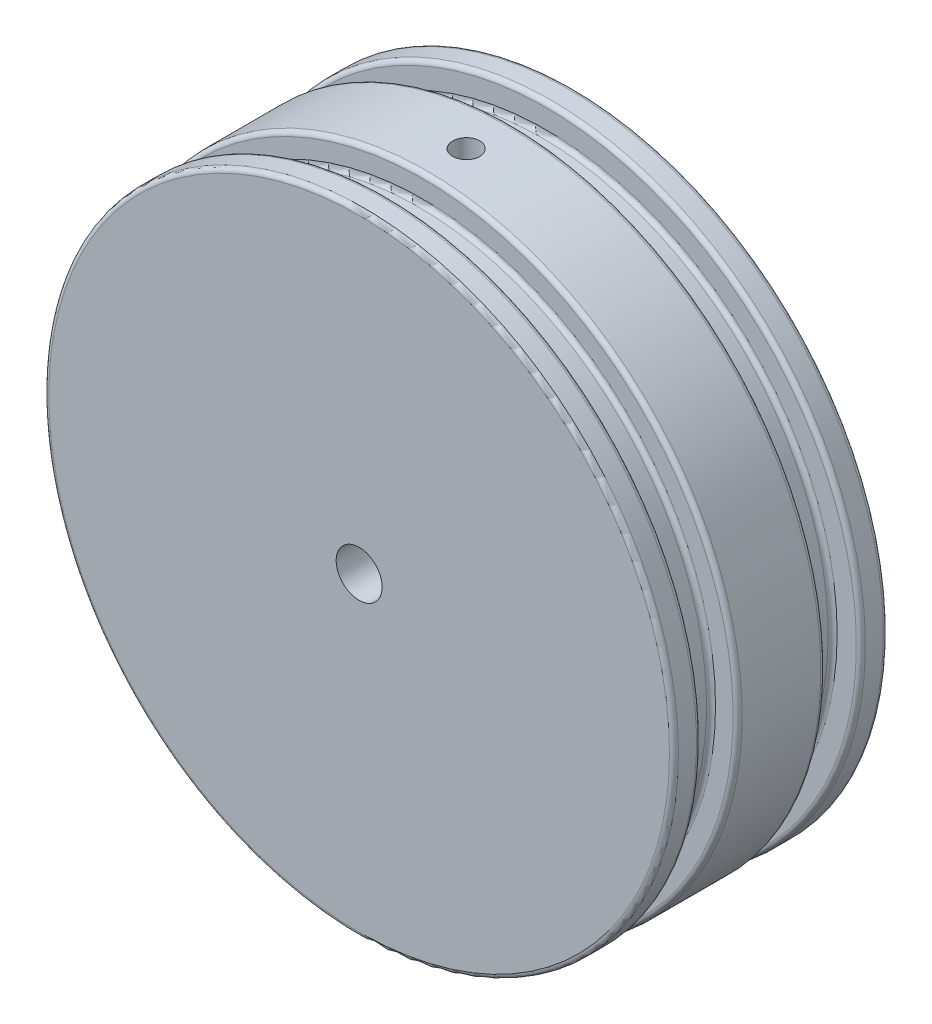
from build123d import *

# Parameters (mm, degrees)
SKETCH1_R                   = 69.9
BOSS_EXTRUDE1_DEPTH         = 20
SKETCH8_R                   = 69.9
BOSS_EXTRUDE2_DEPTH         = 27.5
SKETCH7_W                   = 5.9
SKETCH7_H                   = 8.13
SKETCH7_W_2                 = 6.2648
SKETCH7_H_2                 = 7.87
FILLET1_R                   = 1
M12X1_75_TAPPED_HOLE1_D     = 10.2
M12X1_75_TAPPED_HOLE1_DEPTH = 17.5
M12X1_75_TAPPED_HOLE1_TIP   = 3.064389157
M12X1_75_TAPPED_HOLE2_D     = 10.2
M12X1_75_TAPPED_HOLE2_DEPTH = 17.5
M12X1_75_TAPPED_HOLE2_TIP   = 3.064389157
F_6_0MM_DOWEL_HOLE1_D       = 6
F_6_0MM_DOWEL_HOLE1_DEPTH   = 27
F_6_0MM_DOWEL_HOLE1_TIP     = 1.802581857
F_6_0MM_DOWEL_HOLE2_D       = 6
F_6_0MM_DOWEL_HOLE2_DEPTH   = 23.75
F_6_0MM_DOWEL_HOLE2_TIP     = 1.802581857


with BuildPart() as part:
    # Sketch1 → Boss-Extrude1 (new body)
    with BuildSketch(Plane.XY):
        Circle(SKETCH1_R)
    extrude(amount=BOSS_EXTRUDE1_DEPTH)

    # Sketch8 → Boss-Extrude2 (add)
    with BuildSketch(Plane(origin=(0, 0, 0), x_dir=(-1, 0, 0), z_dir=(0, 0, -1))):
        Circle(SKETCH8_R)
    extrude(amount=BOSS_EXTRUDE2_DEPTH)

    # Sketch7 → Cut-Revolve2 (revolve, cut)
    with BuildSketch(Plane(origin=(0, 0, 0), x_dir=(1, 0, 0), z_dir=(0, 1, 0))):
        with Locations((66.95, -9.935)):
            Rectangle(SKETCH7_W, SKETCH7_H)
        with Locations((66.7676, 17.565)):
            Rectangle(SKETCH7_W_2, SKETCH7_H_2)
    revolve(axis=Axis((0, 0, 0), (0, 0, 1)), mode=Mode.SUBTRACT)

    # Fillet1
    fillet1_edges = [part.edges().sort_by_distance(p)[0] for p in [
        (-69.9, 0, 5.87),
        (-64, 0, 5.87),
        (-64, 0, 14),
        (-69.9, 0, 14),
        (-63.6352, 0, -13.63),
        (69.9, 0, -13.63),
        (69.9, 0, -21.5),
        (-63.6352, 0, -21.5),
        (-69.9, 0, 20),
        (69.9, 0, -27.5),
    ]]
    fillet(fillet1_edges, radius=FILLET1_R)

    # M12x1.75 Tapped Hole1
    with Locations(Plane(origin=(0, 0, -27.5), x_dir=(-1, 0, 0), z_dir=(0, 0, -1))):
        with Locations((0, 0)):
            Hole(M12X1_75_TAPPED_HOLE1_D / 2, depth=M12X1_75_TAPPED_HOLE1_DEPTH)
            with Locations((0, 0, -(M12X1_75_TAPPED_HOLE1_DEPTH + M12X1_75_TAPPED_HOLE1_TIP / 2))):  # 118° drill point
                Cone(0, M12X1_75_TAPPED_HOLE1_D / 2, M12X1_75_TAPPED_HOLE1_TIP, mode=Mode.SUBTRACT)

    # M12x1.75 Tapped Hole2
    with Locations(Plane.XY.offset(20)):
        with Locations((0, 0)):
            Hole(M12X1_75_TAPPED_HOLE2_D / 2, depth=M12X1_75_TAPPED_HOLE2_DEPTH)
            with Locations((0, 0, -(M12X1_75_TAPPED_HOLE2_DEPTH + M12X1_75_TAPPED_HOLE2_TIP / 2))):  # 118° drill point
                Cone(0, M12X1_75_TAPPED_HOLE2_D / 2, M12X1_75_TAPPED_HOLE2_TIP, mode=Mode.SUBTRACT)

    # Ø6.0mm Dowel Hole1
    with Locations(Plane(origin=(0, 69.9, 0), x_dir=(-1, 0, 0), z_dir=(0, 1, 0))):
        with Locations((0, -3.75)):
            Hole(F_6_0MM_DOWEL_HOLE1_D / 2, depth=F_6_0MM_DOWEL_HOLE1_DEPTH)
            with Locations((0, 0, -(F_6_0MM_DOWEL_HOLE1_DEPTH + F_6_0MM_DOWEL_HOLE1_TIP / 2))):  # 118° drill point
                Cone(0, F_6_0MM_DOWEL_HOLE1_D / 2, F_6_0MM_DOWEL_HOLE1_TIP, mode=Mode.SUBTRACT)

    # Ø6.0mm Dowel Hole2
    with Locations(Plane(origin=(0, 0, -27.5), x_dir=(-1, 0, 0), z_dir=(0, 0, -1))):
        with Locations((0, 42.9)):
            Hole(F_6_0MM_DOWEL_HOLE2_D / 2, depth=F_6_0MM_DOWEL_HOLE2_DEPTH)
            with Locations((0, 0, -(F_6_0MM_DOWEL_HOLE2_DEPTH + F_6_0MM_DOWEL_HOLE2_TIP / 2))):  # 118° drill point
                Cone(0, F_6_0MM_DOWEL_HOLE2_D / 2, F_6_0MM_DOWEL_HOLE2_TIP, mode=Mode.SUBTRACT)


solid = part.part
